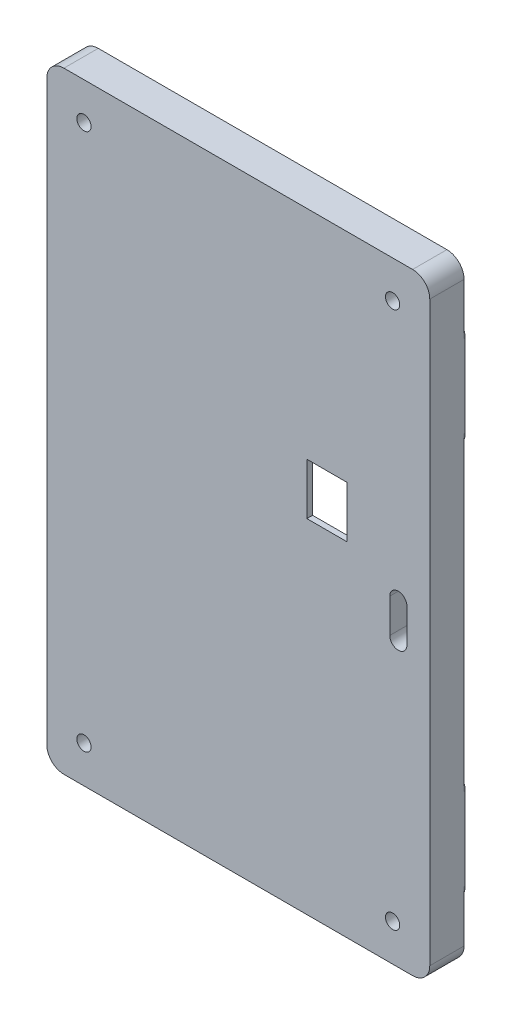
from build123d import *

# Parameters (mm, degrees)
SKICA1_W                 = 67
SKICA1_H                 = 107
P_IDAT_VYSUNUT_M1_DEPTH  = 6
ZAOBLIT1_R               = 3
SKICA2_R                 = 1.25
ODEBRAT_VYSUNUT_M1_DEPTH = 7
ZKOSEN_1_SIZE            = 1.25
SKICA4_W                 = 7
SKICA4_H                 = 9
ODEBRAT_VYSUNUT_M2_DEPTH = 7
SKICA7_W                 = 51
SKICA7_H                 = 87
ODEBRAT_VYSUNUT_M3_DEPTH = 5
SKICA8_W                 = 5
SKICA8_H                 = 5
P_IDAT_VYSUNUT_M2_DEPTH  = 5
SKICA9_R                 = 0.95
ODEBRAT_VYSUNUT_M4_DEPTH = 14
SKICA10_R                = 0.95
ODEBRAT_VYSUNUT_M5_DEPTH = 14
P_IDAT_VYSUNUT_M3_DEPTH  = 0.2


with BuildPart() as part:
    # Skica1 → Přidat vysunutím1 (new body)
    with BuildSketch(Plane.XY):
        with Locations((33.5, 53.5)):
            Rectangle(SKICA1_W, SKICA1_H)
    extrude(amount=P_IDAT_VYSUNUT_M1_DEPTH)

    # Zaoblit1
    zaoblit1_edges = [part.edges().sort_by_distance(p)[0] for p in [
        (0, 107, 3),
        (67, 107, 3),
        (67, 0, 3),
        (0, 0, 3),
    ]]
    fillet(zaoblit1_edges, radius=ZAOBLIT1_R)

    # Skica2 → Odebrat vysunutím1 (cut, through all)
    with BuildSketch(Plane(origin=(0, 0, 0), x_dir=(-1, 0, 0), z_dir=(0, 0, -1))):
        with Locations((-6.5, 100.5)):
            Circle(SKICA2_R)
        with Locations((-60.5, 100.5)):
            Circle(SKICA2_R)
        with Locations((-6.5, 6.5)):
            Circle(SKICA2_R)
        with Locations((-60.5, 6.5)):
            Circle(SKICA2_R)
    extrude(amount=-ODEBRAT_VYSUNUT_M1_DEPTH, mode=Mode.SUBTRACT)

    # Zkosení1
    zkosen_1_edges = [part.edges().sort_by_distance(p)[0] for p in [
        (61.75, 100.5, 0),
        (7.75, 6.5, 0),
        (61.75, 6.5, 0),
        (7.75, 100.5, 0),
    ]]
    chamfer(zkosen_1_edges, length=ZKOSEN_1_SIZE)

    # Skica4 → Odebrat vysunutím2 (cut, through all)
    with BuildSketch(Plane(origin=(0, 0, 0), x_dir=(-1, 0, 0), z_dir=(0, 0, -1))):
        with Locations((-49, 64.5)):
            Rectangle(SKICA4_W, SKICA4_H)
        with BuildLine():
            Line((-60, 55.5), (-60, 49.55))
            ThreePointArc((-60, 49.55), (-61.5, 48.05), (-63, 49.55))
            Line((-63, 49.55), (-63, 55.5))
            ThreePointArc((-63, 55.5), (-61.5, 57), (-60, 55.5))
        make_face()
    extrude(amount=-ODEBRAT_VYSUNUT_M2_DEPTH, mode=Mode.SUBTRACT)

    # Skica7 → Odebrat vysunutím3 (cut)
    with BuildSketch(Plane(origin=(0, 0, 0), x_dir=(-1, 0, 0), z_dir=(0, 0, -1))):
        with Locations((-33.5, 53.5)):
            Rectangle(SKICA7_W, SKICA7_H)
    extrude(amount=-ODEBRAT_VYSUNUT_M3_DEPTH, mode=Mode.SUBTRACT)

    # Skica8 → Přidat vysunutím2 (add)
    with BuildSketch(Plane(origin=(0, 0, 5), x_dir=(-1, 0, 0), z_dir=(0, 0, -1))):
        with Locations((-51.4, 94.5)):
            Rectangle(SKICA8_W, SKICA8_H)
        with Locations((-15.6, 94.5)):
            Rectangle(SKICA8_W, SKICA8_H)
    extrude(amount=P_IDAT_VYSUNUT_M2_DEPTH)

    # Skica9 → Odebrat vysunutím4 (cut)
    with BuildSketch(Plane.ZY.offset(-48.9)):
        with Locations((2.5, 94.5)):
            Circle(SKICA9_R)
    extrude(amount=-ODEBRAT_VYSUNUT_M4_DEPTH, mode=Mode.SUBTRACT)

    # Skica10 → Odebrat vysunutím5 (cut)
    with BuildSketch(Plane(origin=(18.1, 0, 0), x_dir=(0, 0, -1), z_dir=(1, 0, 0))):
        with Locations((-2.5, 94.5)):
            Circle(SKICA10_R)
    extrude(amount=-ODEBRAT_VYSUNUT_M5_DEPTH, mode=Mode.SUBTRACT)

    # Skica11 → Přidat vysunutím3 (add)
    with BuildSketch(Plane(origin=(0, 0, 0), x_dir=(-1, 0, 0), z_dir=(0, 0, -1))):
        with BuildLine():
            Line((0, 95), (0, 80.6))
            ThreePointArc((0, 80.6), (-3.1, 77.5), (-6.2, 80.6))
            Line((-6.2, 80.6), (-6.2, 95))
            ThreePointArc((-6.2, 95), (-3.1, 98.1), (0, 95))
        make_face()
        with BuildLine():
            Line((0, 26.4), (0, 12))
            ThreePointArc((0, 12), (-3.1, 8.9), (-6.2, 12))
            Line((-6.2, 12), (-6.2, 26.4))
            ThreePointArc((-6.2, 26.4), (-3.1, 29.5), (0, 26.4))
        make_face()
        with BuildLine():
            Line((-60.8, 95), (-60.8, 80.6))
            ThreePointArc((-60.8, 80.6), (-63.9, 77.5), (-67, 80.6))
            Line((-67, 80.6), (-67, 95))
            ThreePointArc((-67, 95), (-63.9, 98.1), (-60.8, 95))
        make_face()
        with BuildLine():
            Line((-60.8, 26.4), (-60.8, 12))
            ThreePointArc((-60.8, 12), (-63.9, 8.9), (-67, 12))
            Line((-67, 12), (-67, 26.4))
            ThreePointArc((-67, 26.4), (-63.9, 29.5), (-60.8, 26.4))
        make_face()
    extrude(amount=P_IDAT_VYSUNUT_M3_DEPTH)


solid = part.part
